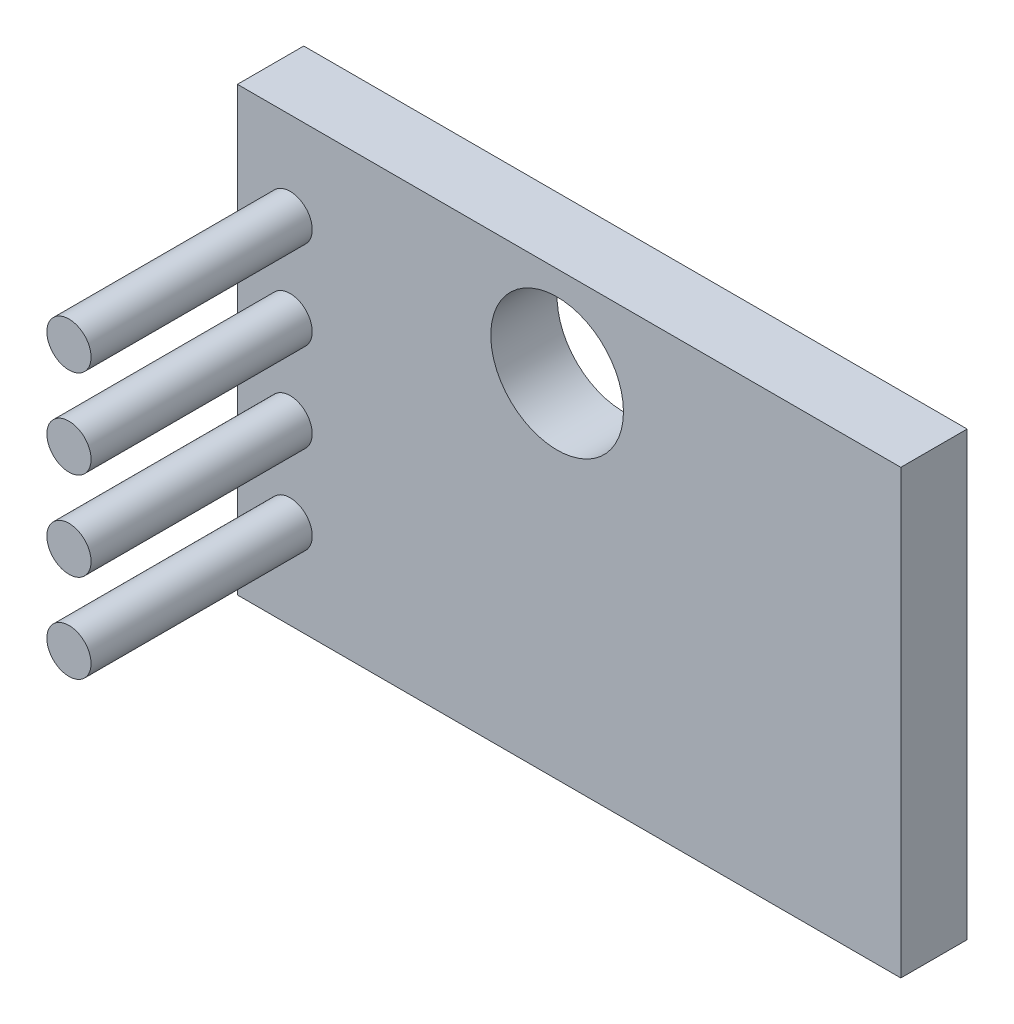
from build123d import *

# Parameters (mm, degrees)
SKETCH1_W           = 15
SKETCH1_H           = 10
SKETCH1_R           = 1.5
BOSS_EXTRUDE1_DEPTH = 1.5
SKETCH2_R           = 0.5
BOSS_EXTRUDE2_DEPTH = 5


with BuildPart() as part:
    # Sketch1 → Boss-Extrude1 (new body)
    with BuildSketch(Plane.XY):
        with Locations((164.083059714, 67.591147655)):
            Rectangle(SKETCH1_W, SKETCH1_H)
        with Locations((163.811741983, 70.542925262)):
            Circle(SKETCH1_R, mode=Mode.SUBTRACT)
    extrude(amount=BOSS_EXTRUDE1_DEPTH)

    # Sketch2 → Boss-Extrude2 (add)
    with BuildSketch(Plane.XY.offset(1.5)):
        with Locations((157.774202419, 68.591147655)):
            Circle(SKETCH2_R)
        with Locations((157.774202419, 70.591147655)):
            Circle(SKETCH2_R)
        with Locations((157.774202419, 64.591147655)):
            Circle(SKETCH2_R)
        with Locations((157.774202419, 66.591147655)):
            Circle(SKETCH2_R)
    extrude(amount=BOSS_EXTRUDE2_DEPTH)


solid = part.part
